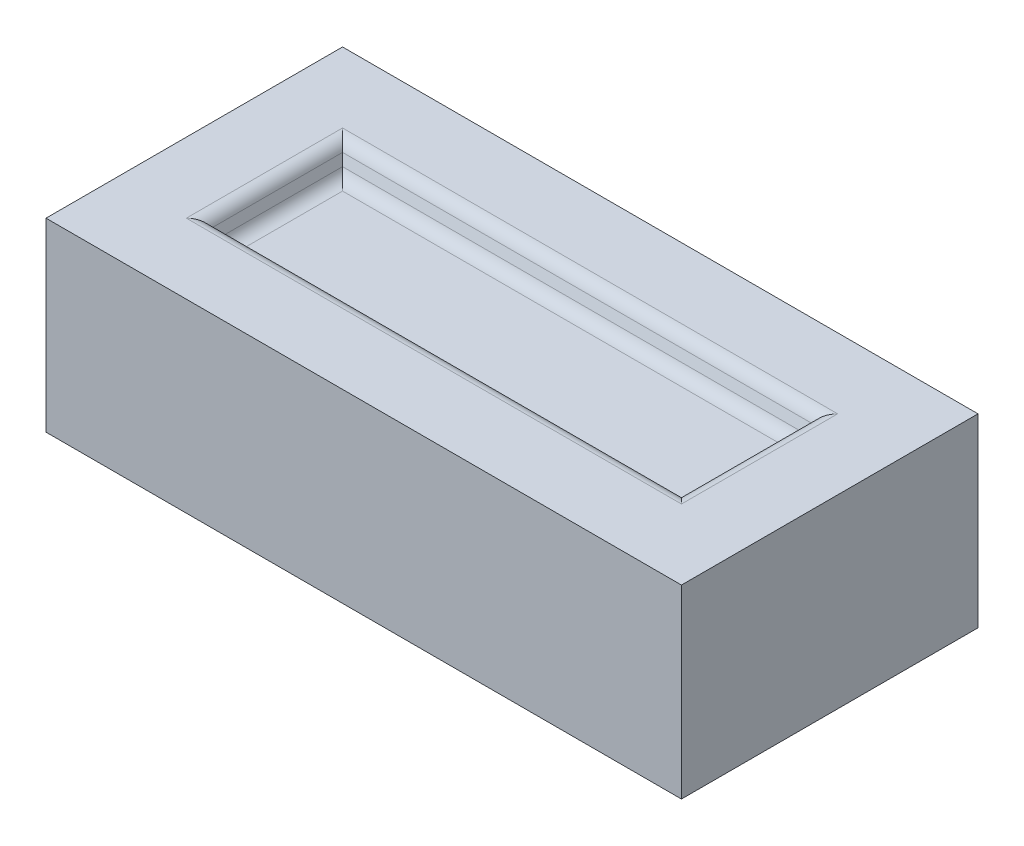
from build123d import *

# Parameters (mm, degrees)
SKETCH1_W           = 240
SKETCH1_H           = 112
BOSS_EXTRUDE1_DEPTH = 70
SKETCH2_W           = 180
SKETCH2_H           = 52
CUT_EXTRUDE1_DEPTH  = 10
CUT_EXTRUDE1_TAPER  = 20
FILLET1_R           = 5


with BuildPart() as part:
    # Sketch1 → Boss-Extrude1 (new body)
    with BuildSketch(Plane(origin=(0, 0, 0), x_dir=(1, 0, 0), z_dir=(0, 1, 0))):
        Rectangle(SKETCH1_W, SKETCH1_H)
    extrude(amount=BOSS_EXTRUDE1_DEPTH)

    # Sketch2 → Cut-Extrude1 (cut)
    with BuildSketch(Plane(origin=(0, 70, 0), x_dir=(1, 0, 0), z_dir=(0, 1, 0))):
        Rectangle(SKETCH2_W, SKETCH2_H)
    cut_extrude1 = extrude(amount=-CUT_EXTRUDE1_DEPTH, taper=CUT_EXTRUDE1_TAPER, mode=Mode.SUBTRACT)

    # Mirror1: Cut-Extrude1 across plane
    add(cut_extrude1.mirror(Plane.ZX.offset(35)), mode=Mode.SUBTRACT)

    # Fillet1
    fillet1_edges = [part.edges().sort_by_distance(p)[0] for p in [
        (86.360297657, 60, 0),
        (0, 60, 22.360297657),
        (-86.360297657, 60, 0),
        (0, 60, -22.360297657),
        (90, 70, 0),
        (0, 70, -26),
        (-90, 70, 0),
        (0, 70, 26),
        (90, 0, 0),
        (0, 0, -26),
        (-90, 0, 0),
        (0, 0, 26),
        (86.360297657, 10, 0),
        (0, 10, -22.360297657),
        (-86.360297657, 10, 0),
        (0, 10, 22.360297657),
    ]]
    fillet(fillet1_edges, radius=FILLET1_R)


solid = part.part
